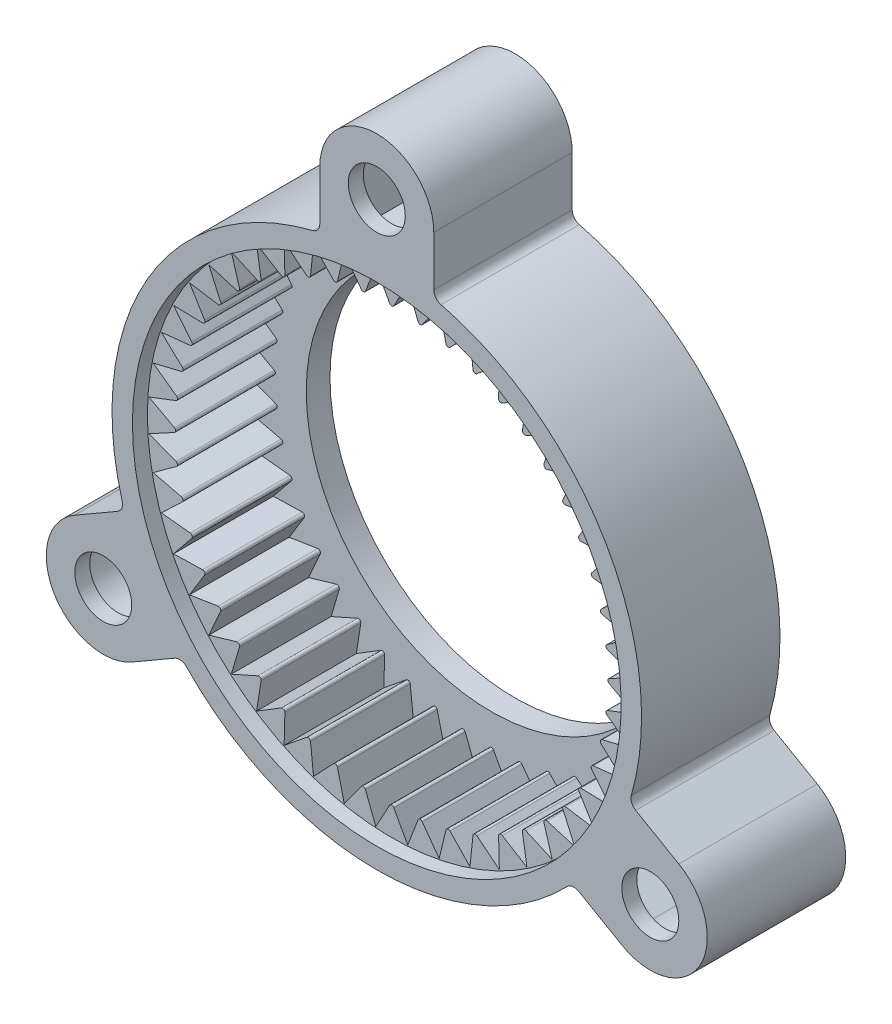
from build123d import *

# Parameters (mm, degrees)
SKETCH3_R                         = 1.524
MOUNT_DEPTH                       = 7.4041
SHELLING_OF_MOUNT_DEPTH           = 6.604
CIRCULAR_PATTERN_FOR_MOUNTS_COUNT = 3
TOUCH_UP_FILLETS_R                = 0.508
TOOTH_DEPTH                       = 5.334
PATTERN_FOR_TEETH_COUNT           = 48


with BuildPart() as part:
    # Sketch1 → Base revolve (revolve)
    with BuildSketch(Plane(origin=(0, 0, 0), x_dir=(0, 0, -1), z_dir=(1, 0, 0))):
        Polygon((0, 14.1605), (0, 13.0683), (6.1341, 13.0683), (6.1341, 9.906), (7.4041, 9.906), (7.4041, 12.2301), (7.9756, 12.2301), (7.9756, 12.8905), (7.4041, 12.8905), (7.4041, 14.1605), align=None)
    revolve(axis=Axis((0, 0, 0), (0, 0, 1)))

    # Sketch3 → Mount (add)
    with BuildSketch(Plane(origin=(0, 0, -7.4041), x_dir=(-1, 0, 0), z_dir=(0, 0, -1))):
        with BuildLine():
            Line((-3.048, 16.891), (-3.048, 13.828573905))
            ThreePointArc((-3.048, 13.828573905), (0, 14.1605), (3.048, 13.828573905))
            Line((3.048, 13.828573905), (3.048, 16.891))
            ThreePointArc((3.048, 16.891), (0, 19.939), (-3.048, 16.891))
        make_face()
        with Locations((0, 16.891)):
            Circle(SKETCH3_R, mode=Mode.SUBTRACT)
    mount = extrude(amount=-MOUNT_DEPTH)

    # Sketch7 → Shelling of mount (cut)
    with BuildSketch(Plane(origin=(0, 0, -7.4041), x_dir=(-1, 0, 0), z_dir=(0, 0, -1))):
        with BuildLine():
            Line((-2.032, 16.891), (-2.032, 14.013947918))
            ThreePointArc((-2.032, 14.013947918), (0, 14.1605), (2.032, 14.013947918))
            Line((2.032, 14.013947918), (2.032, 16.891))
            ThreePointArc((2.032, 16.891), (0, 18.923), (-2.032, 16.891))
        make_face()
    shelling_of_mount = extrude(amount=-SHELLING_OF_MOUNT_DEPTH, mode=Mode.SUBTRACT)

    # Circular pattern for mounts: Mount, Shelling of mount ×3 about axis
    circular_pattern_for_mounts_axis = Axis((0, 0, 0), (0, 0, 1))
    for i in range(1, CIRCULAR_PATTERN_FOR_MOUNTS_COUNT):
        add(mount.rotate(circular_pattern_for_mounts_axis, i * 360 / CIRCULAR_PATTERN_FOR_MOUNTS_COUNT))
        add(shelling_of_mount.rotate(circular_pattern_for_mounts_axis, i * 360 / CIRCULAR_PATTERN_FOR_MOUNTS_COUNT), mode=Mode.SUBTRACT)

    # Touch-up fillets
    touch_up_fillets_edges = [part.edges().sort_by_distance(p)[0] for p in [
        (-3.048, 13.828573905, -3.70205),
        (3.048, 13.828573905, -3.70205),
        (13.4998963, -4.274641522, -3.70205),
        (10.4518963, -9.553932383, -3.70205),
        (-10.4518963, -9.553932383, -3.70205),
        (-13.4998963, -4.274641522, -3.70205),
    ]]
    fillet(touch_up_fillets_edges, radius=TOUCH_UP_FILLETS_R)

    # Sketch8 → Tooth (add)
    with BuildSketch(Plane.XY.offset(-6.1341)):
        with BuildLine():
            Line((-0.111585978, 11.623357033), (-0.9906, 13.240785128))
            Line((-0.9906, 13.240785128), (0.9906, 13.240785128))
            Line((0.9906, 13.240785128), (0.111585978, 11.623357033))
            ThreePointArc((0.111585978, 11.623357033), (0, 11.557), (-0.111585978, 11.623357033))
        make_face()
    tooth = extrude(amount=TOOTH_DEPTH)

    # Pattern for teeth: Tooth ×48 about axis
    pattern_for_teeth_axis = Axis((0, 0, 0), (0, 0, 1))
    for i in range(1, PATTERN_FOR_TEETH_COUNT):
        add(tooth.rotate(pattern_for_teeth_axis, i * 360 / PATTERN_FOR_TEETH_COUNT))


solid = part.part
